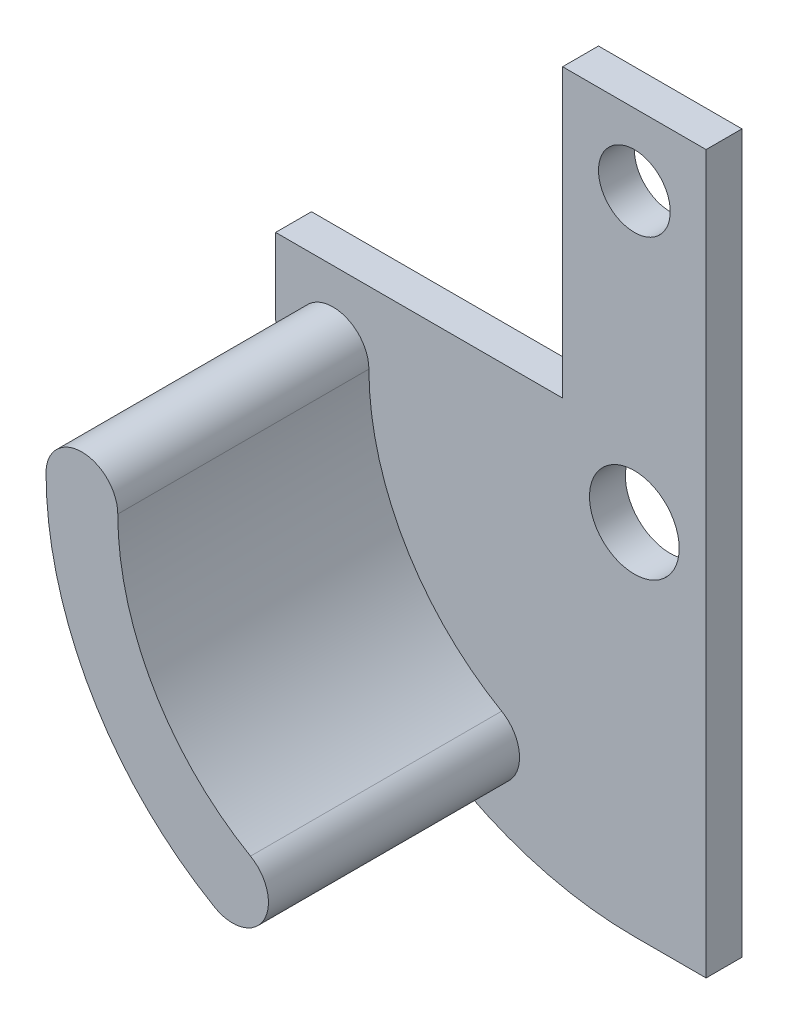
from build123d import *

# Parameters (mm, degrees)
BOSS_EXTRUDE1_DEPTH = 3.175
SKETCH4_R           = 3.96875
SKETCH4_R_2         = 3.175
CUT_EXTRUDE1_DEPTH  = 4.175
BOSS_EXTRUDE3_DEPTH = 22.225


with BuildPart() as part:
    # Sketch1 → Boss-Extrude1 (new body)
    with BuildSketch(Plane.XY):
        with BuildLine():
            Line((-31.75, 0), (-31.75, 6.35))
            Line((-31.75, 6.35), (-6.35, 6.35))
            Line((-6.35, 6.35), (-6.35, 31.75))
            Line((-6.35, 31.75), (6.35, 31.75))
            Line((6.35, 31.75), (6.35, 6.35))
            Line((6.35, 6.35), (6.35, -31.75))
            Line((6.35, -31.75), (0, -31.75))
            ThreePointArc((0, -31.75), (-22.450640303, -22.450640303), (-31.75, 0))
        make_face()
    extrude(amount=BOSS_EXTRUDE1_DEPTH)

    # Sketch4 → Cut-Extrude1 (cut, through all)
    with BuildSketch(Plane.XY.offset(3.175)):
        Circle(SKETCH4_R)
        with Locations((0, 25.4)):
            Circle(SKETCH4_R_2)
    extrude(amount=-CUT_EXTRUDE1_DEPTH, mode=Mode.SUBTRACT)

    # Sketch6 → Boss-Extrude3 (add)
    with BuildSketch(Plane.XY.offset(3.175)):
        with BuildLine():
            ThreePointArc((-29.845, 0), (-26.67, 3.175), (-23.495, 0))
            ThreePointArc((-23.495, 0), (-20.347266862, -11.7475), (-11.7475, -20.347266862))
            ThreePointArc((-11.7475, -20.347266862), (-10.585369343, -24.684397519), (-14.9225, -25.846528176))
            ThreePointArc((-14.9225, -25.846528176), (-25.846528176, -14.9225), (-29.845, 0))
        make_face()
    extrude(amount=BOSS_EXTRUDE3_DEPTH)


solid = part.part
